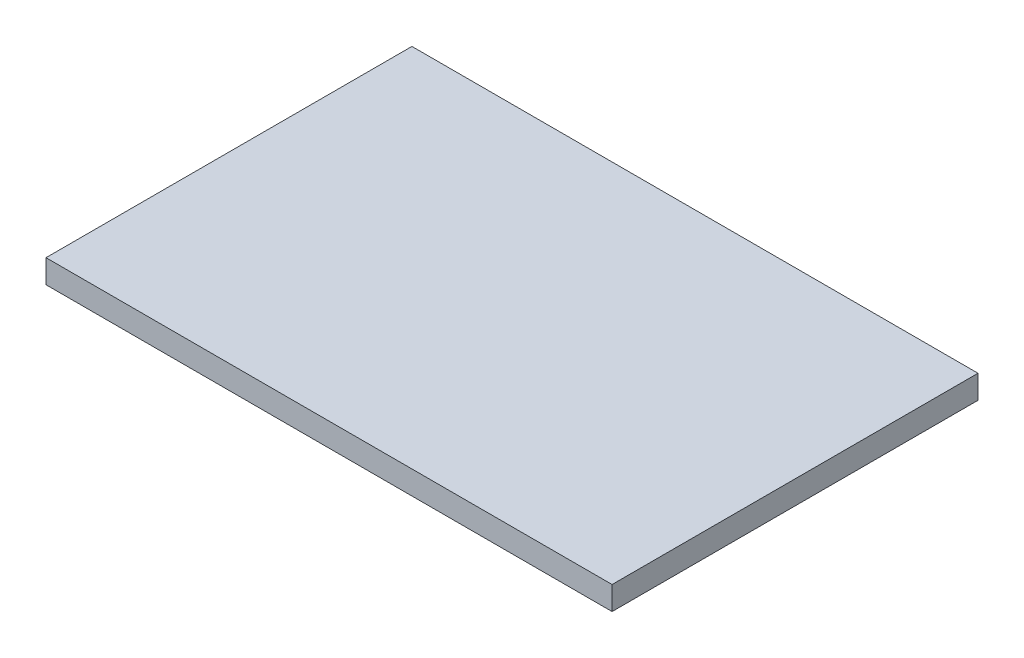
from build123d import *

# Parameters (mm, degrees)
SKETCH1_W           = 36.2
SKETCH1_H           = 23.4
BOSS_EXTRUDE1_DEPTH = 1.5


with BuildPart() as part:
    # Sketch1 → Boss-Extrude1 (new body)
    with BuildSketch(Plane(origin=(0, 0, 0), x_dir=(1, 0, 0), z_dir=(0, 1, 0))):
        with Locations((18.1, 11.7)):
            Rectangle(SKETCH1_W, SKETCH1_H)
    extrude(amount=BOSS_EXTRUDE1_DEPTH)


solid = part.part
